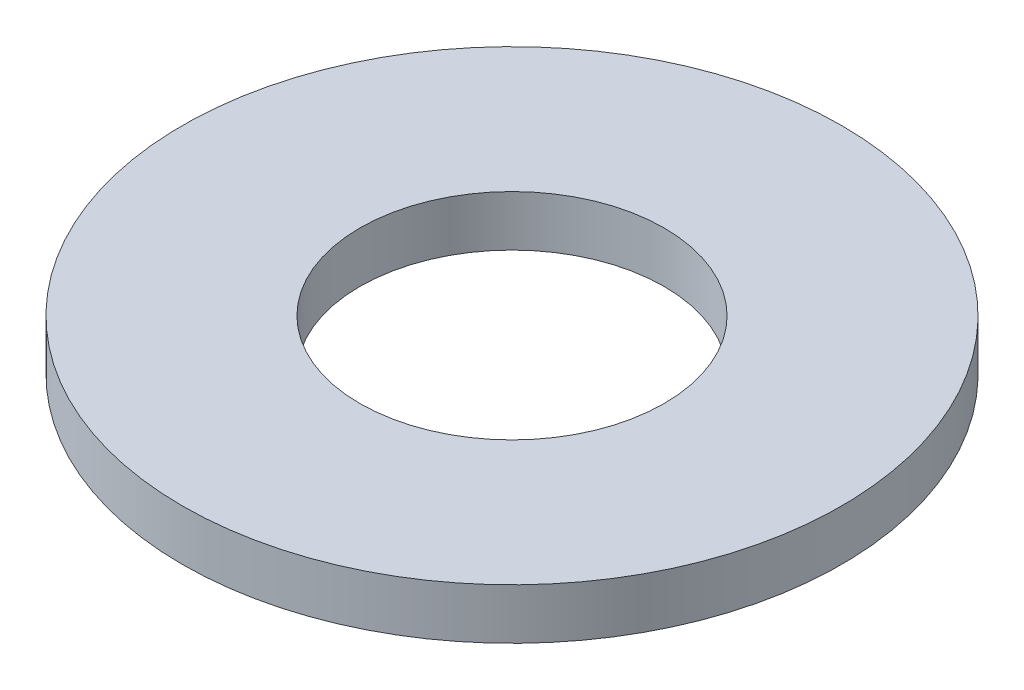
from build123d import *

# Parameters (mm, degrees)
SKETCH_1_R      = 6.5
SKETCH_1_R_2    = 3
EXTRUDE_1_DEPTH = 1


with BuildPart() as part:
    # 草图1 → 凸台-拉伸1 (new body)
    with BuildSketch(Plane(origin=(0, 0, 0), x_dir=(1, 0, 0), z_dir=(0, 1, 0))):
        Circle(SKETCH_1_R)
        Circle(SKETCH_1_R_2, mode=Mode.SUBTRACT)
    extrude(amount=EXTRUDE_1_DEPTH)


solid = part.part
